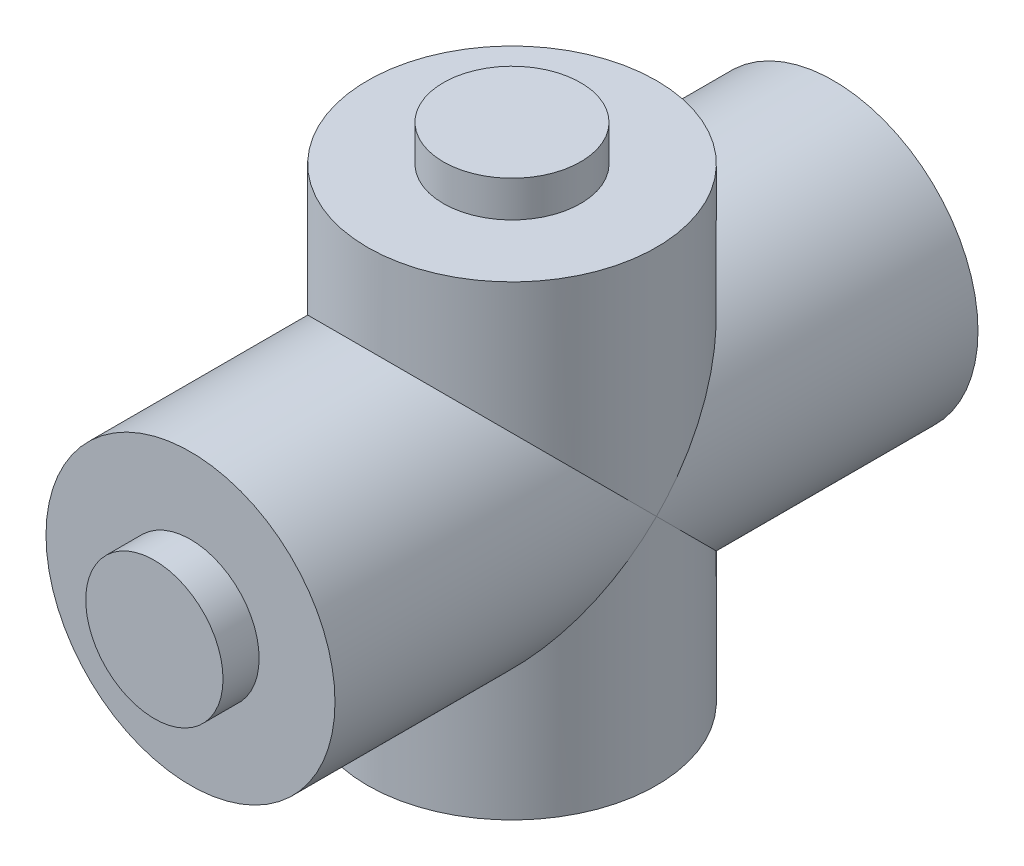
from build123d import *

# Parameters (mm, degrees)
SKETCH_1_R           = 4
EXTRUDE_1_DEPTH      = 17.8
SKETCH_2_R           = 1.9
EXTRUDE_2_DEPTH      = 1
EXTRUDE_START        = 1
SKETCH_3_R           = 1.9
EXTRUDE_3_DEPTH      = 1
EXTRUDE_4_DEPTH      = 6.45
EXTRUDE_4_DEPTH_BACK = 6.45
SKETCH_4_R           = 4
SKETCH_5_R           = 1.9
EXTRUDE_5_DEPTH      = 1
SKETCH_6_R           = 1.9
EXTRUDE_6_DEPTH      = 1


with BuildPart() as part:
    # 草图1 → 凸台-拉伸1 (new body)
    with BuildSketch(Plane.XY):
        Circle(SKETCH_1_R)
    extrude(amount=EXTRUDE_1_DEPTH)

    # 草图2 → 凸台-拉伸2 (add)
    with BuildSketch(Plane.XY.offset(17.8)):
        Circle(SKETCH_2_R)
    extrude(amount=EXTRUDE_2_DEPTH)

    # 草图3 → 凸台-拉伸3 (add)
    with BuildSketch(Plane(origin=(0, 0, 0), x_dir=(-1, 0, 0), z_dir=(0, 0, -1)).offset(EXTRUDE_START)):
        Circle(SKETCH_3_R)
    extrude(amount=-EXTRUDE_3_DEPTH)

    # 草图4 → 凸台-拉伸4 (add, two sides: drawn at the far end of the back side and taken through both)
    with BuildSketch(Plane(origin=(0, 0, 0), x_dir=(1, 0, 0), z_dir=(0, 1, 0)).offset(-EXTRUDE_4_DEPTH_BACK)):
        with Locations((0, -8.9)):
            Circle(SKETCH_4_R)
    extrude(amount=EXTRUDE_4_DEPTH + EXTRUDE_4_DEPTH_BACK)

    # 草图5 → 凸台-拉伸5 (add)
    with BuildSketch(Plane(origin=(0, -6.45, 0), x_dir=(-1, 0, 0), z_dir=(0, -1, 0))):
        with Locations((0, -8.9)):
            Circle(SKETCH_5_R)
    extrude(amount=EXTRUDE_5_DEPTH)

    # 草图6 → 凸台-拉伸6 (add)
    with BuildSketch(Plane(origin=(0, 6.45, 0), x_dir=(1, 0, 0), z_dir=(0, 1, 0)).offset(EXTRUDE_START)):
        with Locations((0, -8.9)):
            Circle(SKETCH_6_R)
    extrude(amount=-EXTRUDE_6_DEPTH)


solid = part.part
